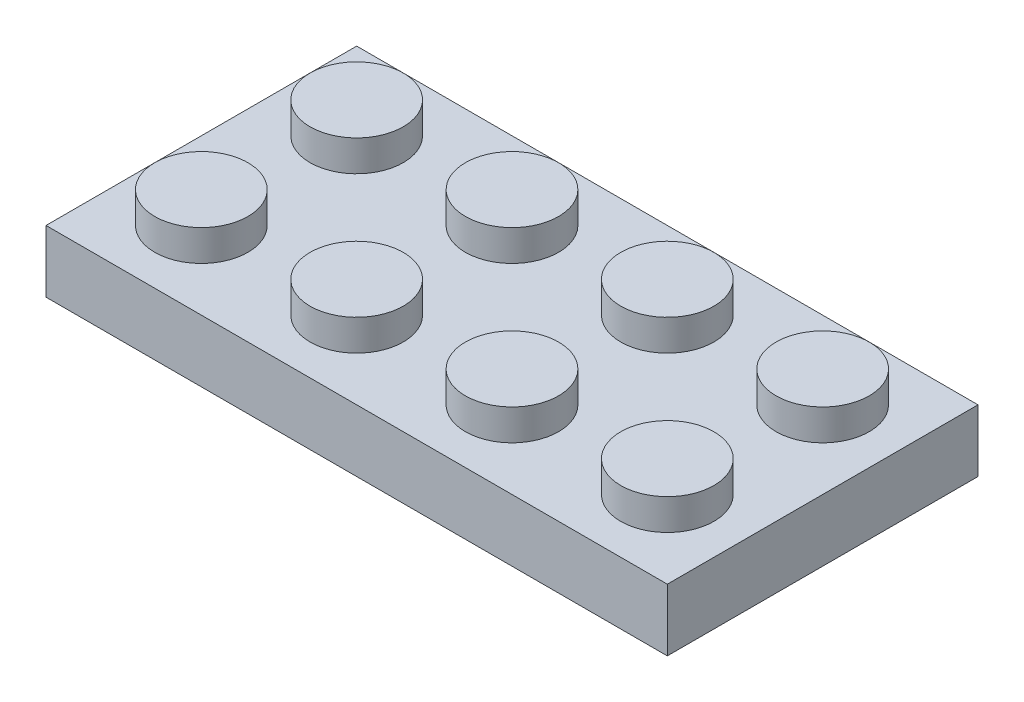
from build123d import *

# Parameters (mm, degrees)
SKETCH1_R             = 1.5
BOSS_EXTRUDE1_DEPTH   = 2
BOSS_EXTRUDE1_2_DEPTH = 2
BOSS_EXTRUDE1_3_DEPTH = 2
BOSS_EXTRUDE1_4_DEPTH = 2
BOSS_EXTRUDE1_5_DEPTH = 2
BOSS_EXTRUDE1_6_DEPTH = 2
BOSS_EXTRUDE1_7_DEPTH = 2
BOSS_EXTRUDE1_8_DEPTH = 2
SKETCH1_3_W           = 20
SKETCH1_3_H           = 10
BOSS_EXTRUDE2_DEPTH   = 1
SKETCH1_4_R           = 0.75
CUT_EXTRUDE1_DEPTH    = 1
SKETCH1_5_W           = 20
SKETCH1_5_H           = 10
SKETCH1_5_W_2         = 18
SKETCH1_5_H_2         = 8
SKETCH1_5_R           = 2.035533906
SKETCH1_5_R_2         = 1.5
BOSS_EXTRUDE3_DEPTH   = 1


with BuildPart() as part:
    # Sketch1 → Boss-Extrude1 (new body)
    with BuildSketch(Plane(origin=(0, 0, 0), x_dir=(1, 0, 0), z_dir=(0, 1, 0))):
        with Locations((-7.5, -2.5)):
            Circle(SKETCH1_R)
    extrude(amount=BOSS_EXTRUDE1_DEPTH)



with BuildPart() as body_2:
    # Sketch1 → Boss-Extrude1 2 (new body)
    with BuildSketch(Plane(origin=(0, 0, 0), x_dir=(1, 0, 0), z_dir=(0, 1, 0))):
        with Locations((-2.5, -2.5)):
            Circle(SKETCH1_R)
    extrude(amount=BOSS_EXTRUDE1_2_DEPTH)


with BuildPart() as body_3:
    # Sketch1 → Boss-Extrude1 3 (new body)
    with BuildSketch(Plane(origin=(0, 0, 0), x_dir=(1, 0, 0), z_dir=(0, 1, 0))):
        with Locations((-7.5, 2.5)):
            Circle(SKETCH1_R)
    extrude(amount=BOSS_EXTRUDE1_3_DEPTH)


with BuildPart() as body_4:
    # Sketch1 → Boss-Extrude1 4 (new body)
    with BuildSketch(Plane(origin=(0, 0, 0), x_dir=(1, 0, 0), z_dir=(0, 1, 0))):
        with Locations((2.5, -2.5)):
            Circle(SKETCH1_R)
    extrude(amount=BOSS_EXTRUDE1_4_DEPTH)


with BuildPart() as body_5:
    # Sketch1 → Boss-Extrude1 5 (new body)
    with BuildSketch(Plane(origin=(0, 0, 0), x_dir=(1, 0, 0), z_dir=(0, 1, 0))):
        with Locations((7.5, -2.5)):
            Circle(SKETCH1_R)
    extrude(amount=BOSS_EXTRUDE1_5_DEPTH)


with BuildPart() as body_6:
    # Sketch1 → Boss-Extrude1 6 (new body)
    with BuildSketch(Plane(origin=(0, 0, 0), x_dir=(1, 0, 0), z_dir=(0, 1, 0))):
        with Locations((-2.5, 2.5)):
            Circle(SKETCH1_R)
    extrude(amount=BOSS_EXTRUDE1_6_DEPTH)


with BuildPart() as body_7:
    # Sketch1 → Boss-Extrude1 7 (new body)
    with BuildSketch(Plane(origin=(0, 0, 0), x_dir=(1, 0, 0), z_dir=(0, 1, 0))):
        with Locations((2.5, 2.5)):
            Circle(SKETCH1_R)
    extrude(amount=BOSS_EXTRUDE1_7_DEPTH)


with BuildPart() as body_8:
    # Sketch1 → Boss-Extrude1 8 (new body)
    with BuildSketch(Plane(origin=(0, 0, 0), x_dir=(1, 0, 0), z_dir=(0, 1, 0))):
        with Locations((7.5, 2.5)):
            Circle(SKETCH1_R)
    extrude(amount=BOSS_EXTRUDE1_8_DEPTH)


with BuildPart() as part_1:
    add(part.part)

    add(body_2.part)  # Boss-Extrude2 merges body 2

    add(body_3.part)  # Boss-Extrude2 merges body 3

    add(body_4.part)  # Boss-Extrude2 merges body 4

    add(body_5.part)  # Boss-Extrude2 merges body 5

    add(body_6.part)  # Boss-Extrude2 merges body 6

    add(body_7.part)  # Boss-Extrude2 merges body 7

    add(body_8.part)  # Boss-Extrude2 merges body 8
    # Sketch1_3 → Boss-Extrude2 (add)
    with BuildSketch(Plane(origin=(0, 0, 0), x_dir=(1, 0, 0), z_dir=(0, 1, 0))):
        Rectangle(SKETCH1_3_W, SKETCH1_3_H)
    extrude(amount=BOSS_EXTRUDE2_DEPTH)

    # Sketch1_4 → Cut-Extrude1 (cut)
    with BuildSketch(Plane(origin=(0, 0, 0), x_dir=(1, 0, 0), z_dir=(0, 1, 0))):
        with Locations((-7.5, 2.5)):
            Circle(SKETCH1_4_R)
        with Locations((-2.5, 2.5)):
            Circle(SKETCH1_4_R)
        with Locations((2.5, 2.5)):
            Circle(SKETCH1_4_R)
        with Locations((7.5, 2.5)):
            Circle(SKETCH1_4_R)
        with Locations((-2.5, -2.5)):
            Circle(SKETCH1_4_R)
        with Locations((2.5, -2.5)):
            Circle(SKETCH1_4_R)
        with Locations((7.5, -2.5)):
            Circle(SKETCH1_4_R)
        with Locations((-7.5, -2.5)):
            Circle(SKETCH1_4_R)
    extrude(amount=CUT_EXTRUDE1_DEPTH, mode=Mode.SUBTRACT)

    # Sketch1_5 → Boss-Extrude3 (add)
    # profile 1 of 4: a face of its own
    with BuildSketch(Plane(origin=(0, 0, 0), x_dir=(1, 0, 0), z_dir=(0, 1, 0))):
        Rectangle(SKETCH1_5_W, SKETCH1_5_H)
        Rectangle(SKETCH1_5_W_2, SKETCH1_5_H_2, mode=Mode.SUBTRACT)
    # profile 2 of 4: a face of its own
    with BuildSketch(Plane(origin=(0, 0, 0), x_dir=(1, 0, 0), z_dir=(0, 1, 0))):
        with Locations((-5, 0)):
            Circle(SKETCH1_5_R)
        with Locations((-5, 0)):
            Circle(SKETCH1_5_R_2, mode=Mode.SUBTRACT)
    # profile 3 of 4: a face of its own
    with BuildSketch(Plane(origin=(0, 0, 0), x_dir=(1, 0, 0), z_dir=(0, 1, 0))):
        Circle(SKETCH1_5_R)
        Circle(SKETCH1_5_R_2, mode=Mode.SUBTRACT)
    # profile 4 of 4: a face of its own
    with BuildSketch(Plane(origin=(0, 0, 0), x_dir=(1, 0, 0), z_dir=(0, 1, 0))):
        with Locations((5, 0)):
            Circle(SKETCH1_5_R)
        with Locations((5, 0)):
            Circle(SKETCH1_5_R_2, mode=Mode.SUBTRACT)
    extrude(amount=-BOSS_EXTRUDE3_DEPTH)


solid = part_1.part
